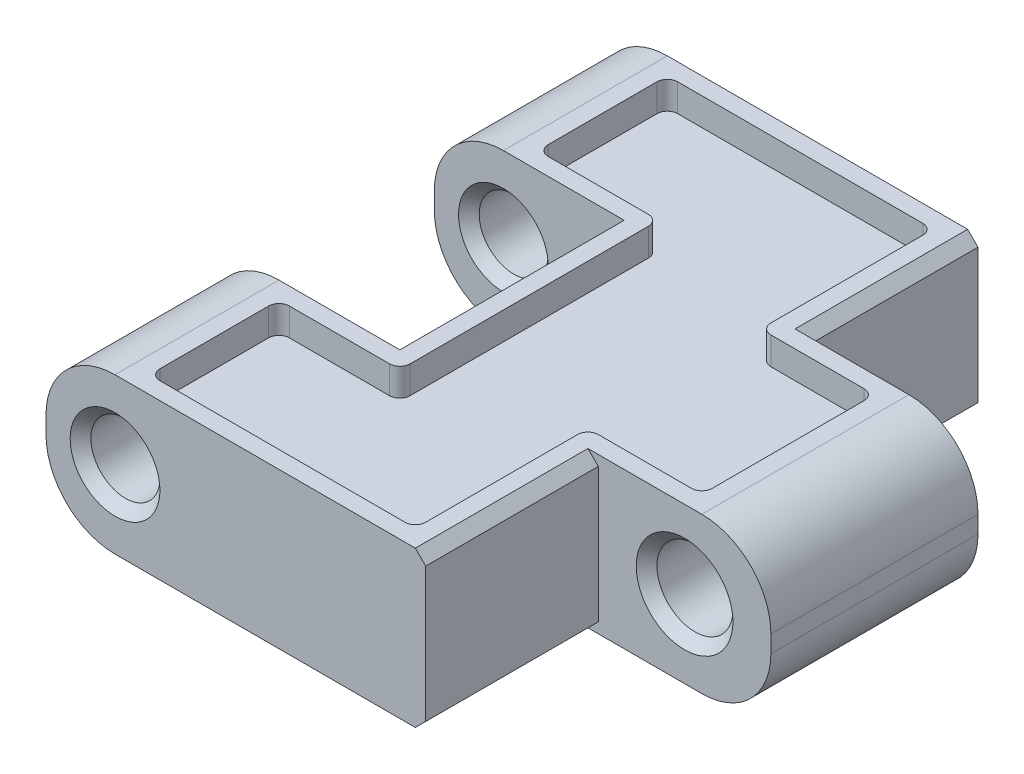
from build123d import *

# Parameters (mm, degrees)
GRUNDK_RPER_DEPTH         = 4.5
SKIZZE2_R                 = 1
SKIZZE2_R_2               = 1.1
ACHSBOHHRUNGEN_DEPTH      = 9
ACHSBOHHRUNGEN_DEPTH_BACK = 9
SKIZZE3_W                 = 2
SKIZZE3_H                 = 6.5
AUSSCHNITT_ZAHN_DEPTH     = 3
VERRUNDUNG2_R             = 2
FASE1_SIZE                = 0.3
FASE2_SIZE                = 0.3
MOOSGUMMIVERTIEFUNG_DEPTH = 0.8
VERRUNDUNG8_R             = 0.3


with BuildPart() as part:
    # Skizze1 → Grundkörper (new body)
    with BuildSketch(Plane(origin=(0, 0, 0), x_dir=(1, 0, 0), z_dir=(0, 1, 0))):
        Polygon((5.5, 3.25), (5.5, -3.25), (0, -3.25), (0, -8), (11, -8), (11, -3), (16, -3), (16, 3), (11, 3), (11, 8), (0, 8), (0, 3.25), align=None)
    extrude(amount=GRUNDK_RPER_DEPTH)

    # Skizze2 → Achsbohhrungen (cut, two sides)
    with BuildSketch(Plane.XY) as achsbohhrungen_sk:
        with Locations((2, 2.25)):
            Circle(SKIZZE2_R)
        with Locations((13.5, 2.25)):
            Circle(SKIZZE2_R_2)
    extrude(amount=ACHSBOHHRUNGEN_DEPTH, mode=Mode.SUBTRACT)
    extrude(achsbohhrungen_sk.sketch, amount=-ACHSBOHHRUNGEN_DEPTH_BACK, mode=Mode.SUBTRACT)

    # Skizze3 → Ausschnitt Zahn (cut)
    with BuildSketch(Plane.XZ):
        with Locations((6.5, 0)):
            Rectangle(SKIZZE3_W, SKIZZE3_H)
    extrude(amount=-AUSSCHNITT_ZAHN_DEPTH, mode=Mode.SUBTRACT)

    # Verrundung2
    verrundung2_edges = [part.edges().sort_by_distance(p)[0] for p in [
        (0, 0, -5.625),
        (16, 0, 0),
        (0, 0, 5.625),
        (16, 4.5, 0),
        (0, 4.5, -5.625),
        (0, 4.5, 5.625),
    ]]
    fillet(verrundung2_edges, radius=VERRUNDUNG2_R)

    # Fase1
    fase1_edges = [part.edges().sort_by_distance(p)[0] for p in [
        (11, 0, -5.5),
        (11, 4.5, 5.5),
        (11, 0, 5.5),
        (11, 4.5, -5.5),
    ]]
    chamfer(fase1_edges, length=FASE1_SIZE)

    # Fase2
    fase2_edges = [part.edges().sort_by_distance(p)[0] for p in [
        (1, 2.25, 3.25),
        (1, 2.25, -8),
        (1, 2.25, -3.25),
        (1, 2.25, 8),
        (12.4, 2.25, -3),
        (12.4, 2.25, 3),
    ]]
    chamfer(fase2_edges, length=FASE2_SIZE)

    # Skizze6 → MoosgummiVertiefung (cut)
    with BuildSketch(Plane(origin=(0, 4.5, 0), x_dir=(1, 0, 0), z_dir=(0, 1, 0))):
        Polygon((13.5, -2.5), (13.5, 2.5), (10.2, 2.5), (10.2, 7.5), (2.5, 7.5), (2.5, 3.75), (6, 3.75), (6, -3.75), (2.5, -3.75), (2.5, -7.5), (10.2, -7.5), (10.2, -2.5), align=None)
    extrude(amount=-MOOSGUMMIVERTIEFUNG_DEPTH, mode=Mode.SUBTRACT)

    # Verrundung8
    verrundung8_edges = [part.edges().sort_by_distance(p)[0] for p in [
        (13.5, 4.1, 2.5),
        (10.2, 4.1, 2.5),
        (10.2, 4.1, 7.5),
        (2.5, 4.1, 7.5),
        (2.5, 4.1, 3.75),
        (6, 4.1, 3.75),
        (6, 4.1, -3.75),
        (2.5, 4.1, -3.75),
        (2.5, 4.1, -7.5),
        (10.2, 4.1, -7.5),
        (10.2, 4.1, -2.5),
        (13.5, 4.1, -2.5),
    ]]
    fillet(verrundung8_edges, radius=VERRUNDUNG8_R)


solid = part.part
